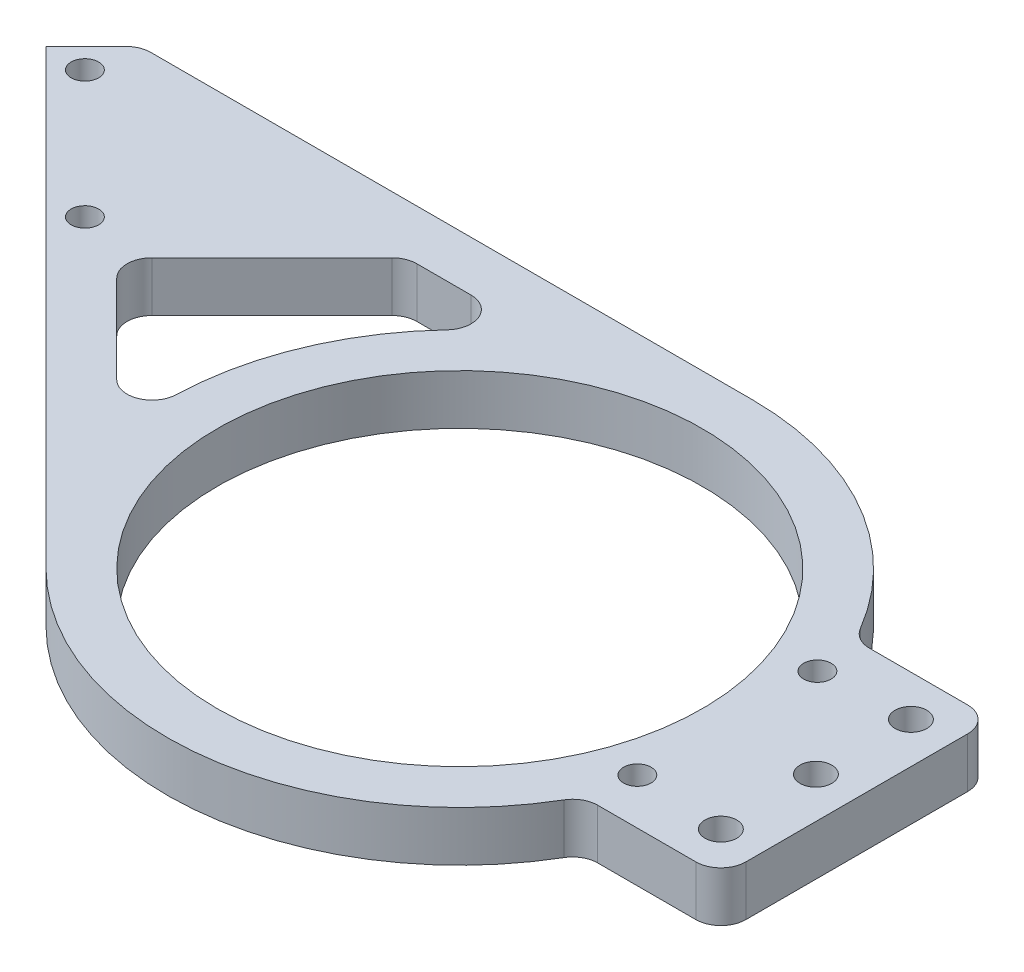
from build123d import *

# Parameters (mm, degrees)
SKETCH1_R                   = 48.5
SKETCH1_R_2                 = 2.75
BOSS_EXTRUDE1_DEPTH         = 5
F_1_4_0_25_DIAMETER_HOLE1_D = 6.35
FILLET1_R                   = 5


with BuildPart() as part:
    # Sketch1 → Boss-Extrude1 (new body, symmetric)
    with BuildSketch(Plane(origin=(0, 0, 0), x_dir=(1, 0, 0), z_dir=(0, 1, 0))):
        with BuildLine():
            Line((-102.265318229, 19.53382483), (-41.365746699, -41.365746699))
            ThreePointArc((-41.365746699, -41.365746699), (8.808484383, -57.833040754), (51.805109545, -27.175))
            Line((51.805109545, -27.175), (79.375, -27.175))
            Line((79.375, -27.175), (79.375, 27.175))
            Line((79.375, 27.175), (51.805109545, 27.175))
            ThreePointArc((51.805109545, 27.175), (30.269724974, 50.059901618), (0, 58.5))
            Line((0, 58.5), (-122.342559288, 58.5))
            Line((-122.342559288, 58.5), (-131.787026344, 49.055532945))
            Line((-131.787026344, 49.055532945), (-102.265318229, 19.53382483))
        make_face()
        Circle(SKETCH1_R, mode=Mode.SUBTRACT)
        with Locations((-123.832075055, 48.87875625)):
            Circle(SKETCH1_R_2, mode=Mode.SUBTRACT)
        with Locations((-98.376230933, 23.422912127)):
            Circle(SKETCH1_R_2, mode=Mode.SUBTRACT)
        with Locations((53.5, 18)):
            Circle(SKETCH1_R_2, mode=Mode.SUBTRACT)
        with Locations((53.5, -18)):
            Circle(SKETCH1_R_2, mode=Mode.SUBTRACT)
        with BuildLine():
            Line((-88.123182605, 19.53382483), (-57.4247459, -11.164611875))
            ThreePointArc((-57.4247459, -11.164611875), (-54.046952652, 22.386980793), (-32.710854468, 48.5))
            Line((-32.710854468, 48.5), (-59.157007436, 48.5))
            Line((-59.157007436, 48.5), (-88.123182605, 19.53382483))
        make_face(mode=Mode.SUBTRACT)
    extrude(amount=BOSS_EXTRUDE1_DEPTH, both=True)

    # 1/4 (0.25) Diameter Hole1 (through all)
    with Locations(Plane(origin=(0, 5, 0), x_dir=(1, 0, 0), z_dir=(0, 1, 0))):
        with Locations((71.2, 19), (71.2, 0), (71.2, -19)):
            Hole(F_1_4_0_25_DIAMETER_HOLE1_D / 2)

    # Fillet1
    fillet1_edges = [part.edges().sort_by_distance(p)[0] for p in [
        (-122.342559288, 0, -58.5),
        (51.805109545, 0, -27.175),
        (79.375, 0, -27.175),
        (79.375, 0, 27.175),
        (51.805109545, 0, 27.175),
        (-88.123182605, 0, -19.53382483),
        (-59.157007436, 0, -48.5),
        (-32.710854468, 0, -48.5),
        (-57.4247459, 0, 11.164611875),
    ]]
    fillet(fillet1_edges, radius=FILLET1_R)


solid = part.part
